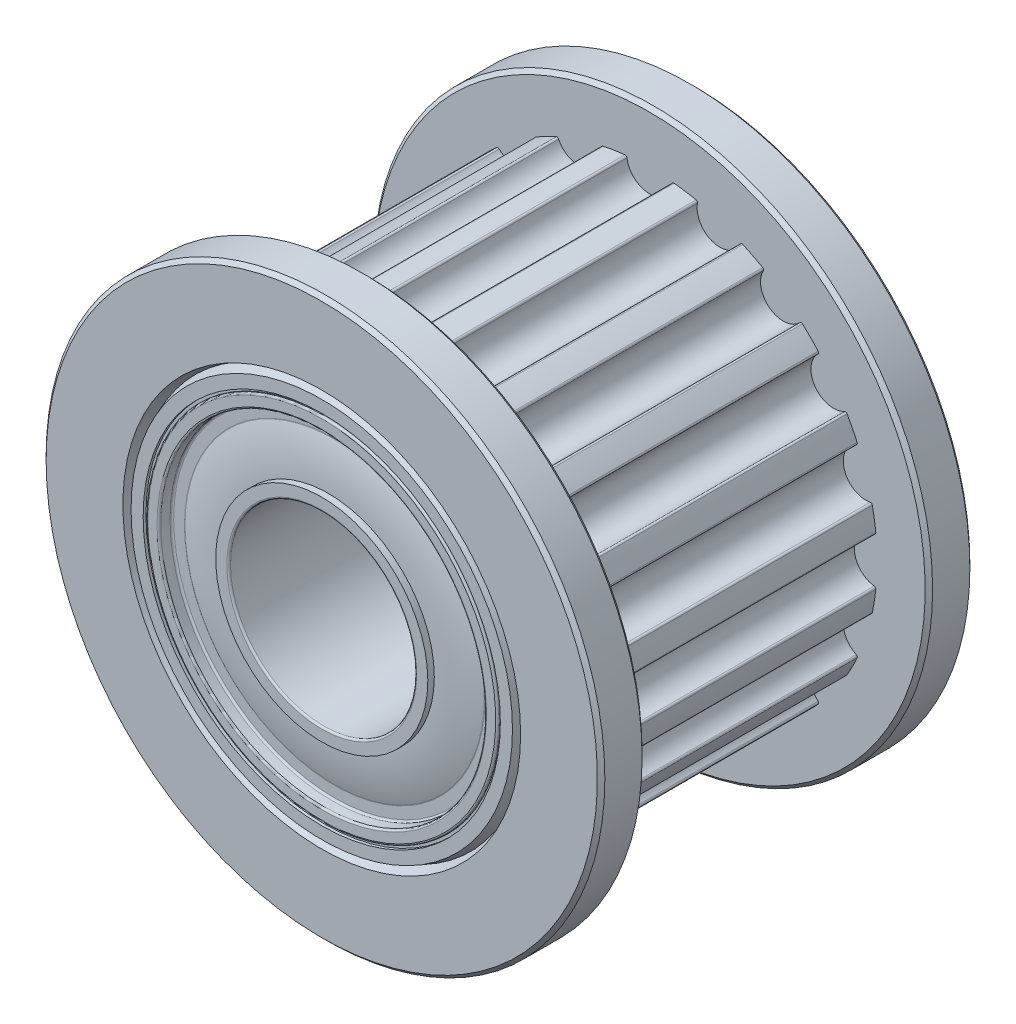
from build123d import *

# Parameters (mm, degrees)
CUT_EXTRUDE1_DEPTH       = 3.8
FILLET1_R                = 0.05
CIRPATTERN3_COUNT        = 20
FILLET1_OF_CIRPATTERN3_R = 0.05
CHAMFER1_SIZE            = 0.1
FILLET2_R                = 0.05


with BuildPart() as part:
    # Sketch2 → Revolve1 (revolve)
    with BuildSketch(Plane(origin=(0, 0, 0), x_dir=(0, 0, -1), z_dir=(1, 0, 0))):
        with BuildLine():
            Line((5, 2.5), (0, 2.5))
            Line((0, 2.5), (0, 4.72))
            Line((0, 4.72), (5, 4.72))
            Line((5, 4.72), (5, 4.3725))
            Line((5, 4.3725), (4.6525, 4.3725))
            Line((4.6525, 4.3725), (4.6525, 4.025))
            ThreePointArc((4.6525, 4.025), (4.782578593, 3.442625053), (4.82625, 2.8475))
            Line((4.82625, 2.8475), (5, 2.8475))
            Line((5, 2.8475), (5, 2.5))
        make_face()
    revolve(axis=Axis((0, 0, 5), (0, 0, -1)))

    # Mirror1: part across plane


with BuildPart() as part_1:
    add(part.part)
    add(part.part.mirror(Plane.XY))

    # Fillet2
    fillet2_edges = [part_1.edges().sort_by_distance(p)[0] for p in [
        (0, -2.5, -5),
        (0, -2.5, 5),
        (0, -4.72, 5),
        (0, -4.3725, 5),
        (0, -4.3725, 4.6525),
        (0, -4.025, 4.6525),
        (0, -2.8475, -5),
        (0, -4.025, -4.6525),
        (0, -4.3725, -5),
        (0, -4.72, -5),
    ]]
    fillet(fillet2_edges, radius=FILLET2_R)


with BuildPart() as body_2:
    # Sketch3 → Revolve2 (revolve)
    with BuildSketch(Plane(origin=(0, 0, 0), x_dir=(0, 0, -1), z_dir=(1, 0, 0))):
        Polygon((3.8, 7.5), (5, 7.5), (5, 5.338382141), (4.7, 5.22919107), (5, 5.12), (5, 4.795), (4.925, 4.795), (4.925, 4.72), (-4.925, 4.72), (-4.925, 4.795), (-5, 4.795), (-5, 5.12), (-4.7, 5.22919107), (-5, 5.338382141), (-5, 7.5), (-3.8, 7.5), (-3.8, 6.11), (3.8, 6.11), align=None)
    revolve(axis=Axis((0, 0, 5), (0, 0, -1)))

    # Sketch4 → Cut-Extrude1 (cut, symmetric)
    with BuildSketch(Plane.XY):
        with BuildLine():
            Line((-0.611, 6.11), (0.611, 6.11))
            ThreePointArc((0.611, 6.11), (0, 5.499), (-0.611, 6.11))
        make_face()
    cut_extrude1 = extrude(amount=CUT_EXTRUDE1_DEPTH, both=True, mode=Mode.SUBTRACT)

    # Fillet1
    fillet1_edges = [body_2.edges().sort_by_distance(p)[0] for p in [
        (0.610235772, 6.07945, 0),
        (-0.610235772, 6.07945, 0),
    ]]
    fillet(fillet1_edges, radius=FILLET1_R)

    # CirPattern3: Cut-Extrude1 ×20 about axis
    cirpattern3_axis = Axis((0, 0, 0), (0, 0, 1))
    for i in range(1, CIRPATTERN3_COUNT):
        add(cut_extrude1.rotate(cirpattern3_axis, i * 360 / CIRPATTERN3_COUNT), mode=Mode.SUBTRACT)

    # Fillet1 of CirPattern3
    fillet1_of_cirpattern3_edges = [body_2.edges().sort_by_distance(p)[0] for p in [
        (-1.298284659, 5.970473762, 0),
        (-2.459022074, 5.593327314, 0),
        (-3.079719942, 5.277065954, 0),
        (-4.067102162, 4.559690779, 0),
        (-4.559690779, 4.067102162, 0),
        (-5.277065954, 3.079719942, 0),
        (-5.593327314, 2.459022074, 0),
        (-5.970473762, 1.298284659, 0),
        (-6.07945, 0.610235772, 0),
        (-6.07945, -0.610235772, 0),
        (-5.970473762, -1.298284659, 0),
        (-5.593327314, -2.459022074, 0),
        (-5.277065954, -3.079719942, 0),
        (-4.559690779, -4.067102162, 0),
        (-4.067102162, -4.559690779, 0),
        (-3.079719942, -5.277065954, 0),
        (-2.459022074, -5.593327314, 0),
        (-1.298284659, -5.970473762, 0),
        (-0.610235772, -6.07945, 0),
        (0.610235772, -6.07945, 0),
        (1.298284659, -5.970473762, 0),
        (2.459022074, -5.593327314, 0),
        (3.079719942, -5.277065954, 0),
        (4.067102162, -4.559690779, 0),
        (4.559690779, -4.067102162, 0),
        (5.277065954, -3.079719942, 0),
        (5.593327314, -2.459022074, 0),
        (5.970473762, -1.298284659, 0),
        (6.07945, -0.610235772, 0),
        (6.07945, 0.610235772, 0),
        (5.970473762, 1.298284659, 0),
        (5.593327314, 2.459022074, 0),
        (5.277065954, 3.079719942, 0),
        (4.559690779, 4.067102162, 0),
        (4.067102162, 4.559690779, 0),
        (3.079719942, 5.277065954, 0),
        (2.459022074, 5.593327314, 0),
        (1.298284659, 5.970473762, 0),
    ]]
    fillet(fillet1_of_cirpattern3_edges, radius=FILLET1_OF_CIRPATTERN3_R)

    # Chamfer1
    chamfer1_edges = [body_2.edges().sort_by_distance(p)[0] for p in [
        (0, -7.5, 3.8),
        (0, -7.5, 5),
        (0, -7.5, -5),
        (0, -7.5, -3.8),
    ]]
    chamfer(chamfer1_edges, length=CHAMFER1_SIZE)

    # Combine1: union part
    add(part_1.part)


solid = body_2.part
